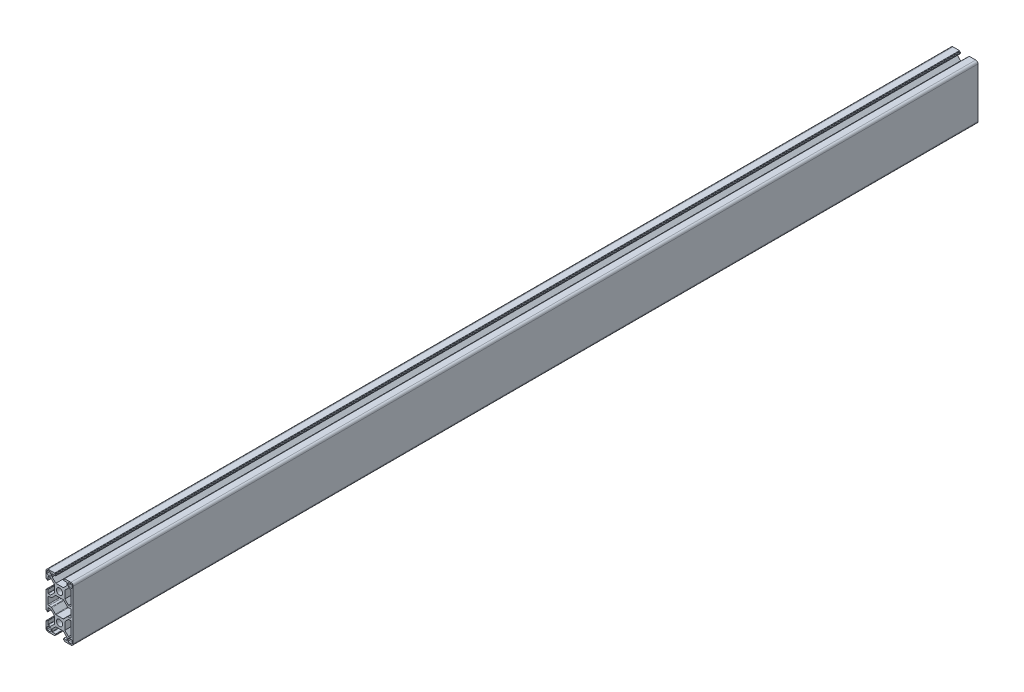
from build123d import *

# Parameters (mm, degrees)
SKETCH_1_R      = 3.4
EXTRUDE_1_DEPTH = 1000


with BuildPart() as part:
    # Эскиз1 → Бобышка-Вытянуть1 (new body)
    with BuildSketch(Plane.XY):
        with BuildLine():
            Line((-15, 12.5), (-15, 5.5))
            ThreePointArc((-15, 5.5), (-14.912132034, 5.287867966), (-14.7, 5.2))
            Line((-14.7, 5.2), (-14.3, 5.2))
            ThreePointArc((-14.3, 5.2), (-14.087867966, 5.112132034), (-14, 4.9))
            Line((-14, 4.9), (-14, 4.4))
            ThreePointArc((-14, 4.4), (-13.912132034, 4.187867966), (-13.7, 4.1))
            Line((-13.7, 4.1), (-13.1, 4.1))
            ThreePointArc((-13.1, 4.1), (-12.887867966, 4.187867966), (-12.8, 4.4))
            Line((-12.8, 4.4), (-12.8, 7.95))
            ThreePointArc((-12.8, 7.95), (-12.712132034, 8.162132034), (-12.5, 8.25))
            Line((-12.5, 8.25), (-9.85, 8.25))
            Line((-9.85, 8.25), (-5.8, 4.2))
            Line((-5.8, 4.2), (-5.8, -4.2))
            Line((-5.8, -4.2), (-9.85, -8.25))
            Line((-9.85, -8.25), (-12.5, -8.25))
            ThreePointArc((-12.5, -8.25), (-12.712132034, -8.162132034), (-12.8, -7.95))
            Line((-12.8, -7.95), (-12.8, -4.4))
            ThreePointArc((-12.8, -4.4), (-12.887867966, -4.187867966), (-13.1, -4.1))
            Line((-13.1, -4.1), (-13.7, -4.1))
            ThreePointArc((-13.7, -4.1), (-13.912132034, -4.187867966), (-14, -4.4))
            Line((-14, -4.4), (-14, -4.9))
            ThreePointArc((-14, -4.9), (-14.087867966, -5.112132034), (-14.3, -5.2))
            Line((-14.3, -5.2), (-14.7, -5.2))
            ThreePointArc((-14.7, -5.2), (-14.912132034, -5.287867966), (-15, -5.5))
            Line((-15, -5.5), (-15, -24.5))
            ThreePointArc((-15, -24.5), (-14.912132034, -24.712132034), (-14.7, -24.8))
            Line((-14.7, -24.8), (-14.3, -24.8))
            ThreePointArc((-14.3, -24.8), (-14.087867966, -24.887867966), (-14, -25.1))
            Line((-14, -25.1), (-14, -25.6))
            ThreePointArc((-14, -25.6), (-13.912132034, -25.812132034), (-13.7, -25.9))
            Line((-13.7, -25.9), (-13.1, -25.9))
            ThreePointArc((-13.1, -25.9), (-12.887867966, -25.812132034), (-12.8, -25.6))
            Line((-12.8, -25.6), (-12.8, -22.05))
            ThreePointArc((-12.8, -22.05), (-12.712132034, -21.837867966), (-12.5, -21.75))
            Line((-12.5, -21.75), (-9.85, -21.75))
            Line((-9.85, -21.75), (-5.8, -25.8))
            Line((-5.8, -25.8), (-5.8, -34.2))
            Line((-5.8, -34.2), (-9.85, -38.25))
            Line((-9.85, -38.25), (-12.5, -38.25))
            ThreePointArc((-12.5, -38.25), (-12.712132034, -38.162132034), (-12.8, -37.95))
            Line((-12.8, -37.95), (-12.8, -34.4))
            ThreePointArc((-12.8, -34.4), (-12.887867966, -34.187867966), (-13.1, -34.1))
            Line((-13.1, -34.1), (-13.7, -34.1))
            ThreePointArc((-13.7, -34.1), (-13.912132034, -34.187867966), (-14, -34.4))
            Line((-14, -34.4), (-14, -34.9))
            ThreePointArc((-14, -34.9), (-14.087867966, -35.112132034), (-14.3, -35.2))
            Line((-14.3, -35.2), (-14.7, -35.2))
            ThreePointArc((-14.7, -35.2), (-14.912132034, -35.287867966), (-15, -35.5))
            Line((-15, -35.5), (-15, -42.5))
            ThreePointArc((-15, -42.5), (-14.267766953, -44.267766953), (-12.5, -45))
            Line((-12.5, -45), (-5.5, -45))
            ThreePointArc((-5.5, -45), (-5.287867966, -44.912132034), (-5.2, -44.7))
            Line((-5.2, -44.7), (-5.2, -44.3))
            ThreePointArc((-5.2, -44.3), (-5.112132034, -44.087867966), (-4.9, -44))
            Line((-4.9, -44), (-4.4, -44))
            ThreePointArc((-4.4, -44), (-4.187867966, -43.912132034), (-4.1, -43.7))
            Line((-4.1, -43.7), (-4.1, -43.1))
            ThreePointArc((-4.1, -43.1), (-4.187867966, -42.887867966), (-4.4, -42.8))
            Line((-4.4, -42.8), (-7.95, -42.8))
            ThreePointArc((-7.95, -42.8), (-8.162132034, -42.712132034), (-8.25, -42.5))
            Line((-8.25, -42.5), (-8.25, -39.85))
            Line((-8.25, -39.85), (-4.2, -35.8))
            Line((-4.2, -35.8), (4.2, -35.8))
            Line((4.2, -35.8), (8.25, -39.85))
            Line((8.25, -39.85), (8.25, -42.5))
            ThreePointArc((8.25, -42.5), (8.162132034, -42.712132034), (7.95, -42.8))
            Line((7.95, -42.8), (4.4, -42.8))
            ThreePointArc((4.4, -42.8), (4.187867966, -42.887867966), (4.1, -43.1))
            Line((4.1, -43.1), (4.1, -43.7))
            ThreePointArc((4.1, -43.7), (4.187867966, -43.912132034), (4.4, -44))
            Line((4.4, -44), (4.9, -44))
            ThreePointArc((4.9, -44), (5.112132034, -44.087867966), (5.2, -44.3))
            Line((5.2, -44.3), (5.2, -44.7))
            ThreePointArc((5.2, -44.7), (5.287867966, -44.912132034), (5.5, -45))
            Line((5.5, -45), (12.5, -45))
            ThreePointArc((12.5, -45), (14.267766953, -44.267766953), (15, -42.5))
            Line((15, -42.5), (15, 12.5))
            ThreePointArc((15, 12.5), (14.267766953, 14.267766953), (12.5, 15))
            Line((12.5, 15), (5.5, 15))
            ThreePointArc((5.5, 15), (5.287867966, 14.912132034), (5.2, 14.7))
            Line((5.2, 14.7), (5.2, 14.3))
            ThreePointArc((5.2, 14.3), (5.112132034, 14.087867966), (4.9, 14))
            Line((4.9, 14), (4.4, 14))
            ThreePointArc((4.4, 14), (4.187867966, 13.912132034), (4.1, 13.7))
            Line((4.1, 13.7), (4.1, 13.1))
            ThreePointArc((4.1, 13.1), (4.187867966, 12.887867966), (4.4, 12.8))
            Line((4.4, 12.8), (7.95, 12.8))
            ThreePointArc((7.95, 12.8), (8.162132034, 12.712132034), (8.25, 12.5))
            Line((8.25, 12.5), (8.25, 9.85))
            Line((8.25, 9.85), (4.2, 5.8))
            Line((4.2, 5.8), (-4.2, 5.8))
            Line((-4.2, 5.8), (-8.25, 9.85))
            Line((-8.25, 9.85), (-8.25, 12.5))
            ThreePointArc((-8.25, 12.5), (-8.162132034, 12.712132034), (-7.95, 12.8))
            Line((-7.95, 12.8), (-4.4, 12.8))
            ThreePointArc((-4.4, 12.8), (-4.187867966, 12.887867966), (-4.1, 13.1))
            Line((-4.1, 13.1), (-4.1, 13.7))
            ThreePointArc((-4.1, 13.7), (-4.187867966, 13.912132034), (-4.4, 14))
            Line((-4.4, 14), (-4.9, 14))
            ThreePointArc((-4.9, 14), (-5.112132034, 14.087867966), (-5.2, 14.3))
            Line((-5.2, 14.3), (-5.2, 14.7))
            ThreePointArc((-5.2, 14.7), (-5.287867966, 14.912132034), (-5.5, 15))
            Line((-5.5, 15), (-12.5, 15))
            ThreePointArc((-12.5, 15), (-14.267766953, 14.267766953), (-15, 12.5))
        make_face()
        with BuildLine():
            ThreePointArc((12.8, -37.95), (12.712132034, -38.162132034), (12.5, -38.25))
            Line((12.5, -38.25), (9.85, -38.25))
            Line((9.85, -38.25), (5.8, -34.2))
            Line((5.8, -34.2), (5.8, -25.8))
            Line((5.8, -25.8), (9.85, -21.75))
            Line((9.85, -21.75), (12.5, -21.75))
            ThreePointArc((12.5, -21.75), (12.712132034, -21.837867966), (12.8, -22.05))
            Line((12.8, -22.05), (12.8, -37.95))
        make_face(mode=Mode.SUBTRACT)
        with BuildLine():
            Line((12.8, 7.95), (12.8, -7.95))
            ThreePointArc((12.8, -7.95), (12.712132034, -8.162132034), (12.5, -8.25))
            Line((12.5, -8.25), (9.85, -8.25))
            Line((9.85, -8.25), (5.8, -4.2))
            Line((5.8, -4.2), (5.8, 4.2))
            Line((5.8, 4.2), (9.85, 8.25))
            Line((9.85, 8.25), (12.5, 8.25))
            ThreePointArc((12.5, 8.25), (12.712132034, 8.162132034), (12.8, 7.95))
        make_face(mode=Mode.SUBTRACT)
        with BuildLine():
            Line((-9.55, -40.55), (-9.55, -42.75))
            ThreePointArc((-9.55, -42.75), (-9.842893219, -43.457106781), (-10.55, -43.75))
            Line((-10.55, -43.75), (-12.75, -43.75))
            ThreePointArc((-12.75, -43.75), (-13.457106781, -43.457106781), (-13.75, -42.75))
            Line((-13.75, -42.75), (-13.75, -40.55))
            ThreePointArc((-13.75, -40.55), (-13.457106781, -39.842893219), (-12.75, -39.55))
            Line((-12.75, -39.55), (-10.55, -39.55))
            ThreePointArc((-10.55, -39.55), (-9.842893219, -39.842893219), (-9.55, -40.55))
        make_face(mode=Mode.SUBTRACT)
        with Locations((0, -30)):
            Circle(SKETCH_1_R, mode=Mode.SUBTRACT)
        with BuildLine():
            ThreePointArc((-11.8, -19.5), (-12.507106781, -19.207106781), (-12.8, -18.5))
            Line((-12.8, -18.5), (-12.8, -11.5))
            ThreePointArc((-12.8, -11.5), (-12.507106781, -10.792893219), (-11.8, -10.5))
            Line((-11.8, -10.5), (-9.402943725, -10.5))
            ThreePointArc((-9.402943725, -10.5), (-9.020260293, -10.423879533), (-8.695836944, -10.207106781))
            Line((-8.695836944, -10.207106781), (-4.581623382, -6.092893219))
            ThreePointArc((-4.581623382, -6.092893219), (-4.257200033, -5.876120467), (-3.8745166, -5.8))
            Line((-3.8745166, -5.8), (3.8745166, -5.8))
            ThreePointArc((3.8745166, -5.8), (4.257200033, -5.876120467), (4.581623382, -6.092893219))
            Line((4.581623382, -6.092893219), (8.695836944, -10.207106781))
            ThreePointArc((8.695836944, -10.207106781), (9.020260293, -10.423879533), (9.402943725, -10.5))
            Line((9.402943725, -10.5), (11.8, -10.5))
            ThreePointArc((11.8, -10.5), (12.507106781, -10.792893219), (12.8, -11.5))
            Line((12.8, -11.5), (12.8, -18.5))
            ThreePointArc((12.8, -18.5), (12.507106781, -19.207106781), (11.8, -19.5))
            Line((11.8, -19.5), (9.402943725, -19.5))
            ThreePointArc((9.402943725, -19.5), (9.020260293, -19.576120467), (8.695836944, -19.792893219))
            Line((8.695836944, -19.792893219), (4.581623382, -23.907106781))
            ThreePointArc((4.581623382, -23.907106781), (4.257200033, -24.123879533), (3.8745166, -24.2))
            Line((3.8745166, -24.2), (-3.8745166, -24.2))
            ThreePointArc((-3.8745166, -24.2), (-4.257200033, -24.123879533), (-4.581623382, -23.907106781))
            Line((-4.581623382, -23.907106781), (-8.695836944, -19.792893219))
            ThreePointArc((-8.695836944, -19.792893219), (-9.020260293, -19.576120467), (-9.402943725, -19.5))
            Line((-9.402943725, -19.5), (-11.8, -19.5))
        make_face(mode=Mode.SUBTRACT)
        with BuildLine():
            ThreePointArc((10.55, -43.75), (9.842893219, -43.457106781), (9.55, -42.75))
            Line((9.55, -42.75), (9.55, -40.55))
            ThreePointArc((9.55, -40.55), (9.842893219, -39.842893219), (10.55, -39.55))
            Line((10.55, -39.55), (12.75, -39.55))
            ThreePointArc((12.75, -39.55), (13.457106781, -39.842893219), (13.75, -40.55))
            Line((13.75, -40.55), (13.75, -42.75))
            ThreePointArc((13.75, -42.75), (13.457106781, -43.457106781), (12.75, -43.75))
            Line((12.75, -43.75), (10.55, -43.75))
        make_face(mode=Mode.SUBTRACT)
        Circle(SKETCH_1_R, mode=Mode.SUBTRACT)
        with BuildLine():
            ThreePointArc((-13.75, 12.75), (-13.457106781, 13.457106781), (-12.75, 13.75))
            Line((-12.75, 13.75), (-10.55, 13.75))
            ThreePointArc((-10.55, 13.75), (-9.842893219, 13.457106781), (-9.55, 12.75))
            Line((-9.55, 12.75), (-9.55, 10.55))
            ThreePointArc((-9.55, 10.55), (-9.842893219, 9.842893219), (-10.55, 9.55))
            Line((-10.55, 9.55), (-12.75, 9.55))
            ThreePointArc((-12.75, 9.55), (-13.457106781, 9.842893219), (-13.75, 10.55))
            Line((-13.75, 10.55), (-13.75, 12.75))
        make_face(mode=Mode.SUBTRACT)
        with BuildLine():
            ThreePointArc((13.75, 10.55), (13.457106781, 9.842893219), (12.75, 9.55))
            Line((12.75, 9.55), (10.55, 9.55))
            ThreePointArc((10.55, 9.55), (9.842893219, 9.842893219), (9.55, 10.55))
            Line((9.55, 10.55), (9.55, 12.75))
            ThreePointArc((9.55, 12.75), (9.842893219, 13.457106781), (10.55, 13.75))
            Line((10.55, 13.75), (12.75, 13.75))
            ThreePointArc((12.75, 13.75), (13.457106781, 13.457106781), (13.75, 12.75))
            Line((13.75, 12.75), (13.75, 10.55))
        make_face(mode=Mode.SUBTRACT)
    extrude(amount=EXTRUDE_1_DEPTH)


solid = part.part
